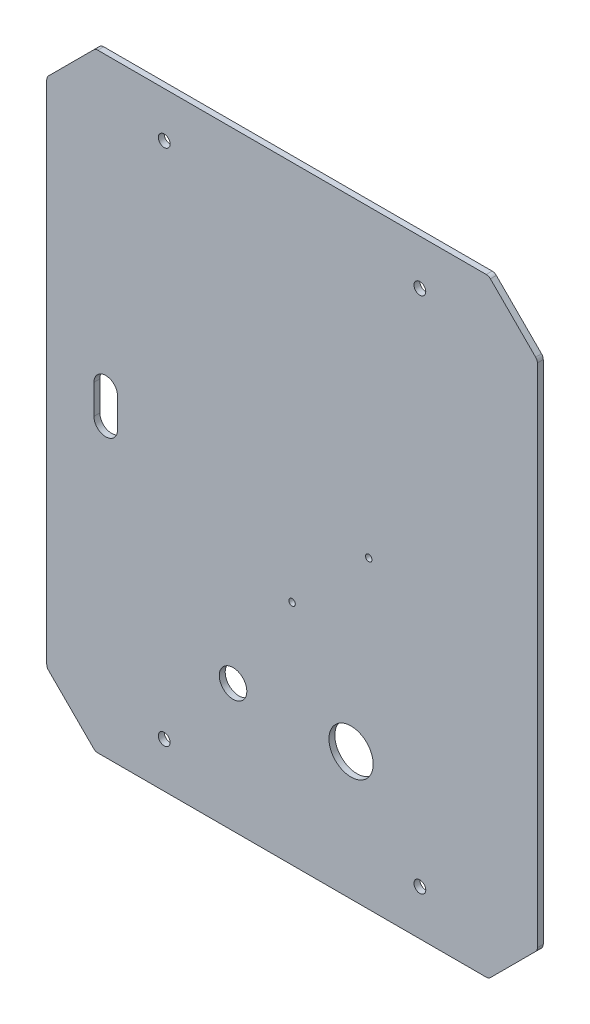
from build123d import *

# Parameters (mm, degrees)
BASE_DEPTH                     = 3
CONG_1_R                       = 3
ESQUISSE20_R                   = 3
PER_AGE_PROFIL_S_DEPTH         = 4
ESQUISSE21_R                   = 1.65
PER_AGE_LIDAR_DEPTH            = 4
ESQUISSE22_R                   = 11.25
PER_AGE_ARRET_D_URGENCE_DEPTH  = 4
ESQUISSE23_R                   = 7
PER_AGE_TIRETTE_DEPTH          = 4
PER_AGE_CABLE_MANAGEMENT_DEPTH = 4


with BuildPart() as part:
    # Esquisse1 → Base (new body)
    with BuildSketch(Plane.XY):
        Polygon((0, 0), (-200, 0), (-224.748737342, 24.748737342), (-224.748737342, 284.748737342), (-200, 309.497474683), (0, 309.497474683), (24.748737342, 284.748737342), (24.748737342, 24.748737342), align=None)
    extrude(amount=BASE_DEPTH)

    # Congé1
    cong_1_edges = [part.edges().sort_by_distance(p)[0] for p in [
        (0, 0, 1.5),
        (-200, 0, 1.5),
        (-224.748737342, 24.748737342, 1.5),
        (-224.748737342, 284.748737342, 1.5),
        (-200, 309.497474683, 1.5),
        (0, 309.497474683, 1.5),
        (24.748737342, 284.748737342, 1.5),
        (24.748737342, 24.748737342, 1.5),
    ]]
    fillet(cong_1_edges, radius=CONG_1_R)

    # Esquisse20 → Perçage Profilés (cut, through all)
    with BuildSketch(Plane(origin=(0, 0, 0), x_dir=(-1, 0, 0), z_dir=(0, 0, -1))):
        with Locations((35, 286.497474683)):
            Circle(ESQUISSE20_R)
        with Locations((165, 286.497474683)):
            Circle(ESQUISSE20_R)
        with Locations((165, 23)):
            Circle(ESQUISSE20_R)
        with Locations((35, 23)):
            Circle(ESQUISSE20_R)
    extrude(amount=-PER_AGE_PROFIL_S_DEPTH, mode=Mode.SUBTRACT)

    # Esquisse21 → Perçage Lidar (cut, through all)
    with BuildSketch(Plane(origin=(0, 0, 0), x_dir=(-1, 0, 0), z_dir=(0, 0, -1))):
        with Locations((61, 154.748737342)):
            Circle(ESQUISSE21_R)
        with Locations((100, 115.748737342)):
            Circle(ESQUISSE21_R)
    extrude(amount=-PER_AGE_LIDAR_DEPTH, mode=Mode.SUBTRACT)

    # Esquisse22 → Perçage Arret d'urgence (cut, through all)
    with BuildSketch(Plane(origin=(0, 0, 0), x_dir=(-1, 0, 0), z_dir=(0, 0, -1))):
        with Locations((70, 65)):
            Circle(ESQUISSE22_R)
    extrude(amount=-PER_AGE_ARRET_D_URGENCE_DEPTH, mode=Mode.SUBTRACT)

    # Esquisse23 → Perçage Tirette (cut, through all)
    with BuildSketch(Plane(origin=(0, 0, 0), x_dir=(-1, 0, 0), z_dir=(0, 0, -1))):
        with Locations((130, 65)):
            Circle(ESQUISSE23_R)
    extrude(amount=-PER_AGE_TIRETTE_DEPTH, mode=Mode.SUBTRACT)

    # Esquisse24 → Perçage Cable management (cut, through all)
    with BuildSketch(Plane(origin=(0, 0, 0), x_dir=(-1, 0, 0), z_dir=(0, 0, -1))):
        with BuildLine():
            Line((188.748737342, 147.248737342), (188.748737342, 162.248737342))
            ThreePointArc((188.748737342, 162.248737342), (194.748737342, 168.248737342), (200.748737342, 162.248737342))
            Line((200.748737342, 162.248737342), (200.748737342, 147.248737342))
            ThreePointArc((200.748737342, 147.248737342), (194.748737342, 141.248737342), (188.748737342, 147.248737342))
        make_face()
    extrude(amount=-PER_AGE_CABLE_MANAGEMENT_DEPTH, mode=Mode.SUBTRACT)


solid = part.part
